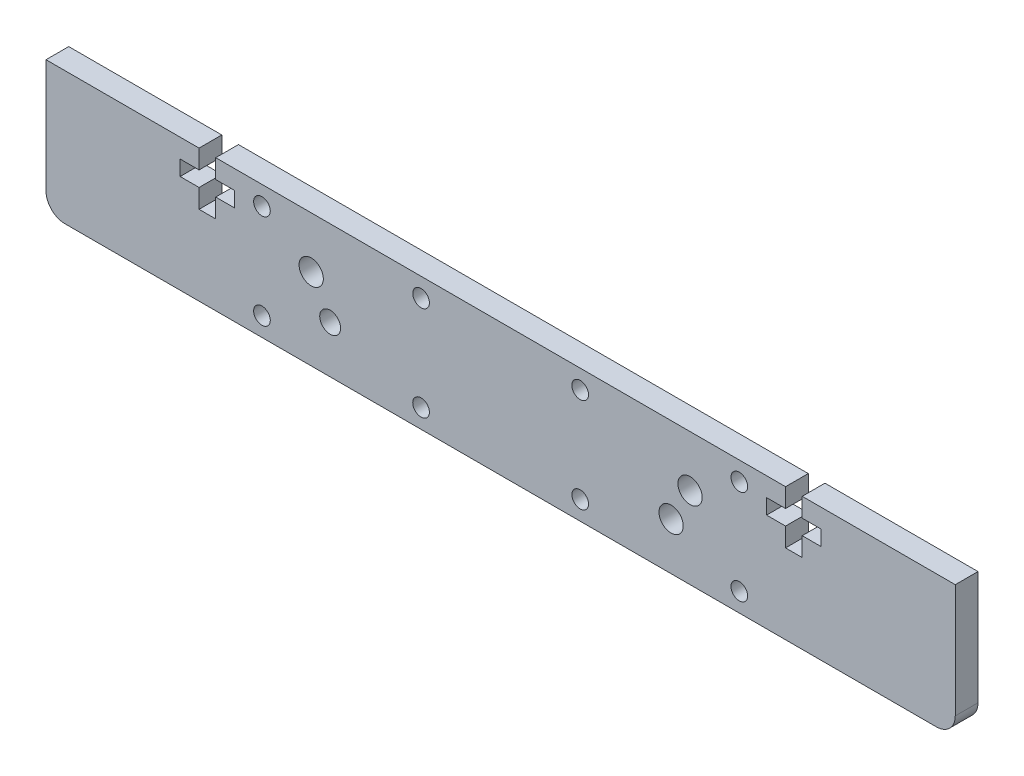
from build123d import *

# Parameters (mm, degrees)
SKETCH1_R           = 1.1
SKETCH1_R_2         = 1.6
SKETCH1_R_3         = 1.375
BOSS_EXTRUDE1_DEPTH = 3
FILLET1_R           = 2.5


with BuildPart() as part:
    # Sketch1 → Boss-Extrude1 (new body)
    with BuildSketch(Plane.XY):
        Polygon((-60, -8.75), (60, -8.75), (60, 8.75), (39.8, 8.75), (39.8, 6.25), (42.3, 6.25), (42.3, 4.25), (39.8, 4.25), (39.8, 1.75), (37.6, 1.75), (37.6, 4.25), (35.1, 4.25), (35.1, 6.25), (37.6, 6.25), (37.6, 8.75), (-37.6, 8.75), (-37.6, 6.25), (-35.1, 6.25), (-35.1, 4.25), (-37.6, 4.25), (-37.6, 1.75), (-39.8, 1.75), (-39.8, 4.25), (-42.3, 4.25), (-42.3, 6.25), (-39.8, 6.25), (-39.8, 8.75), (-60, 8.75), align=None)
        with Locations((-10.5, 6.25)):
            Circle(SKETCH1_R, mode=Mode.SUBTRACT)
        with Locations((-10.5, -6.25)):
            Circle(SKETCH1_R, mode=Mode.SUBTRACT)
        with Locations((10.5, -6.25)):
            Circle(SKETCH1_R, mode=Mode.SUBTRACT)
        with Locations((10.5, 6.25)):
            Circle(SKETCH1_R, mode=Mode.SUBTRACT)
        with Locations((-31.5, 6.25)):
            Circle(SKETCH1_R, mode=Mode.SUBTRACT)
        with Locations((-31.5, -6.25)):
            Circle(SKETCH1_R, mode=Mode.SUBTRACT)
        with Locations((31.5, -6.25)):
            Circle(SKETCH1_R, mode=Mode.SUBTRACT)
        with Locations((31.5, 6.25)):
            Circle(SKETCH1_R, mode=Mode.SUBTRACT)
        with Locations((25, 2)):
            Circle(SKETCH1_R_2, mode=Mode.SUBTRACT)
        with Locations((-25, 2)):
            Circle(SKETCH1_R_2, mode=Mode.SUBTRACT)
        with Locations((22.5, -2.5)):
            Circle(SKETCH1_R_2, mode=Mode.SUBTRACT)
        with Locations((-22.5, -2.5)):
            Circle(SKETCH1_R_3, mode=Mode.SUBTRACT)
    extrude(amount=BOSS_EXTRUDE1_DEPTH)

    # Fillet1
    fillet1_edges = [part.edges().sort_by_distance(p)[0] for p in [
        (60, -8.75, 1.5),
        (-60, -8.75, 1.5),
    ]]
    fillet(fillet1_edges, radius=FILLET1_R)


solid = part.part
